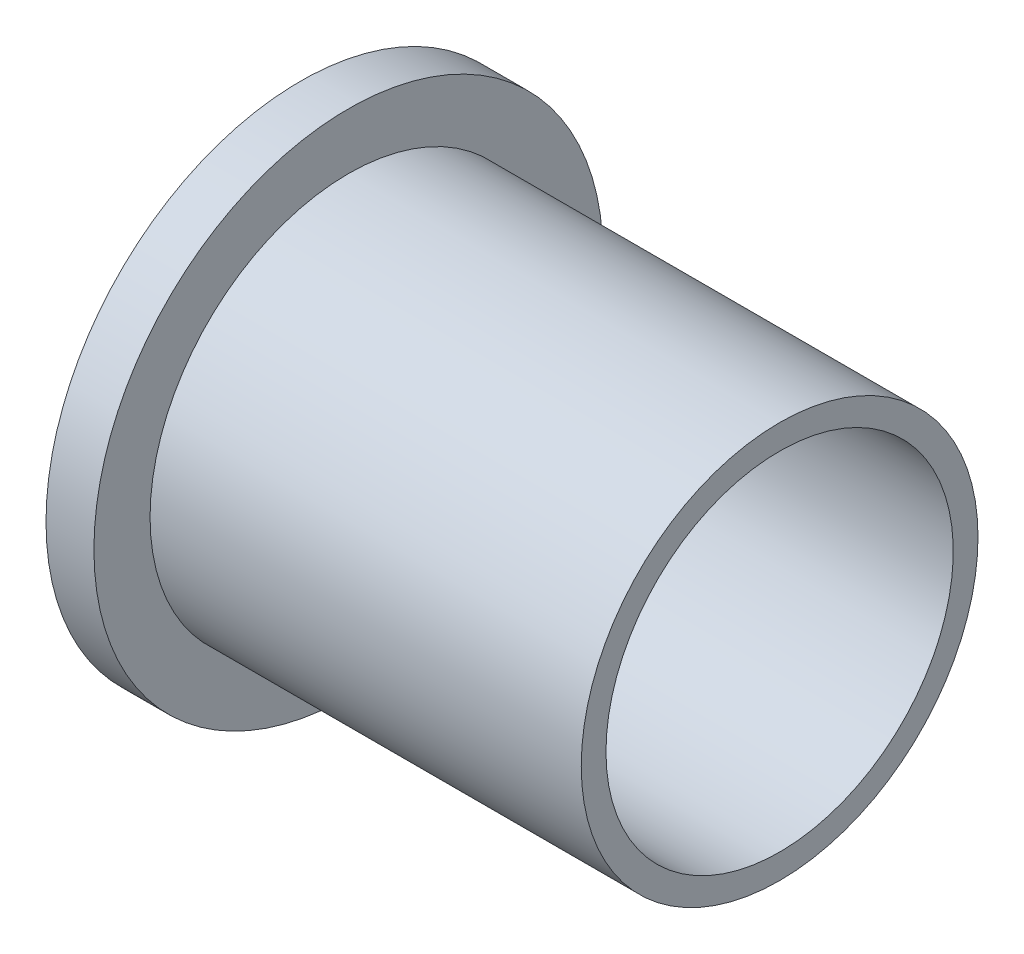
from build123d import *


with BuildPart() as part:
    # Crossection → Revolve 2 (revolve)
    with BuildSketch(Plane.XY):
        Polygon((0, 107.95), (0, 73.6473), (203.2, 73.6473), (203.2, 84.1375), (20.32, 84.1375), (20.32, 107.95), align=None)
    revolve(axis=Axis((0, 0, 0), (1, 0, 0)))


solid = part.part
